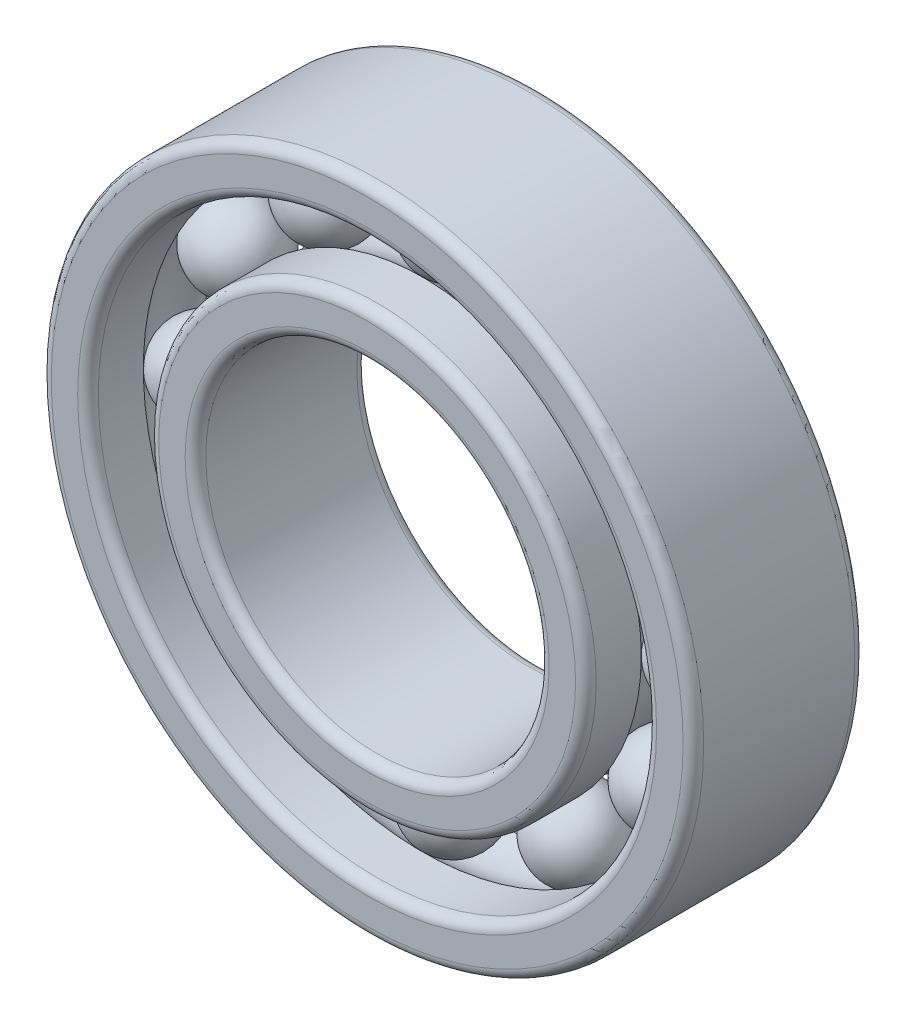
from build123d import *

# Parameters (mm, degrees)
KREISMUSTER4_COUNT = 12
VERRUNDUNG1_R      = 0.3
VERRUNDUNG2_R      = 0.3


with BuildPart() as part:
    # Skizze1 → Rotation1 (revolve)
    with BuildSketch(Plane(origin=(0, 0, 0), x_dir=(0, 0, -1), z_dir=(1, 0, 0))):
        with BuildLine():
            Line((2.5, 9.5), (-2.5, 9.5))
            Line((-2.5, 9.5), (-2.5, 8.13))
            Line((-2.5, 8.13), (-0.887749965, 8.13))
            ThreePointArc((-0.887749965, 8.13), (0, 8.5), (0.887749965, 8.13))
            Line((0.887749965, 8.13), (2.5, 8.13))
            Line((2.5, 8.13), (2.5, 9.5))
        make_face()
        with BuildLine():
            ThreePointArc((0.887749965, 6.37), (0, 6), (-0.887749965, 6.37))
            Line((-0.887749965, 6.37), (-2.5, 6.37))
            Line((-2.5, 6.37), (-2.5, 5))
            Line((-2.5, 5), (2.5, 5))
            Line((2.5, 5), (2.5, 6.37))
            Line((2.5, 6.37), (0.887749965, 6.37))
        make_face()
    revolve(axis=Axis((0, 0, 0), (0, 0, -1)))

    # Verrundung1
    verrundung1_edges = [part.edges().sort_by_distance(p)[0] for p in [
        (0, -8.13, -2.5),
        (0, -8.13, 2.5),
        (0, -9.5, -2.5),
        (0, -9.5, 2.5),
    ]]
    fillet(verrundung1_edges, radius=VERRUNDUNG1_R)

    # Verrundung2
    verrundung2_edges = [part.edges().sort_by_distance(p)[0] for p in [
        (0, -6.37, -2.5),
        (0, -5, -2.5),
        (0, -6.37, 2.5),
        (0, -5, 2.5),
    ]]
    fillet(verrundung2_edges, radius=VERRUNDUNG2_R)


with BuildPart() as body_2:
    # Skizze1_5 → Rotation3 (revolve)
    with BuildSketch(Plane(origin=(0, 0, 0), x_dir=(0, 0, -1), z_dir=(1, 0, 0))):
        with BuildLine():
            ThreePointArc((0.887749965, 8.13), (0, 8.5), (-0.887749965, 8.13))
            ThreePointArc((-0.887749965, 8.13), (-1.155895206, 7.725821681), (-1.25, 7.25))
            Line((-1.25, 7.25), (1.25, 7.25))
            ThreePointArc((1.25, 7.25), (1.155895206, 7.725821681), (0.887749965, 8.13))
        make_face()
    revolve(axis=Axis((0, 7.25, 1.25), (0, 0, -1)))


with BuildPart() as kreismuster4_1:
    # Kreismuster4: pattern copy
    add(body_2.part.rotate(Axis((0, 0, -2.5), (0, 0, 1)), 1 * 360 / KREISMUSTER4_COUNT))


with BuildPart() as kreismuster4_2:
    # Kreismuster4: pattern copy
    add(body_2.part.rotate(Axis((0, 0, -2.5), (0, 0, 1)), 2 * 360 / KREISMUSTER4_COUNT))


with BuildPart() as kreismuster4_3:
    # Kreismuster4: pattern copy
    add(body_2.part.rotate(Axis((0, 0, -2.5), (0, 0, 1)), 3 * 360 / KREISMUSTER4_COUNT))


with BuildPart() as kreismuster4_4:
    # Kreismuster4: pattern copy
    add(body_2.part.rotate(Axis((0, 0, -2.5), (0, 0, 1)), 4 * 360 / KREISMUSTER4_COUNT))


with BuildPart() as kreismuster4_5:
    # Kreismuster4: pattern copy
    add(body_2.part.rotate(Axis((0, 0, -2.5), (0, 0, 1)), 5 * 360 / KREISMUSTER4_COUNT))


with BuildPart() as kreismuster4_6:
    # Kreismuster4: pattern copy
    add(body_2.part.rotate(Axis((0, 0, -2.5), (0, 0, 1)), 6 * 360 / KREISMUSTER4_COUNT))


with BuildPart() as kreismuster4_7:
    # Kreismuster4: pattern copy
    add(body_2.part.rotate(Axis((0, 0, -2.5), (0, 0, 1)), 7 * 360 / KREISMUSTER4_COUNT))


with BuildPart() as kreismuster4_8:
    # Kreismuster4: pattern copy
    add(body_2.part.rotate(Axis((0, 0, -2.5), (0, 0, 1)), 8 * 360 / KREISMUSTER4_COUNT))


with BuildPart() as kreismuster4_9:
    # Kreismuster4: pattern copy
    add(body_2.part.rotate(Axis((0, 0, -2.5), (0, 0, 1)), 9 * 360 / KREISMUSTER4_COUNT))


with BuildPart() as kreismuster4_10:
    # Kreismuster4: pattern copy
    add(body_2.part.rotate(Axis((0, 0, -2.5), (0, 0, 1)), 10 * 360 / KREISMUSTER4_COUNT))


with BuildPart() as kreismuster4_11:
    # Kreismuster4: pattern copy
    add(body_2.part.rotate(Axis((0, 0, -2.5), (0, 0, 1)), 11 * 360 / KREISMUSTER4_COUNT))


solid = Compound([part.part, body_2.part, kreismuster4_1.part, kreismuster4_2.part, kreismuster4_3.part, kreismuster4_4.part, kreismuster4_5.part, kreismuster4_6.part, kreismuster4_7.part, kreismuster4_8.part, kreismuster4_9.part, kreismuster4_10.part, kreismuster4_11.part])
